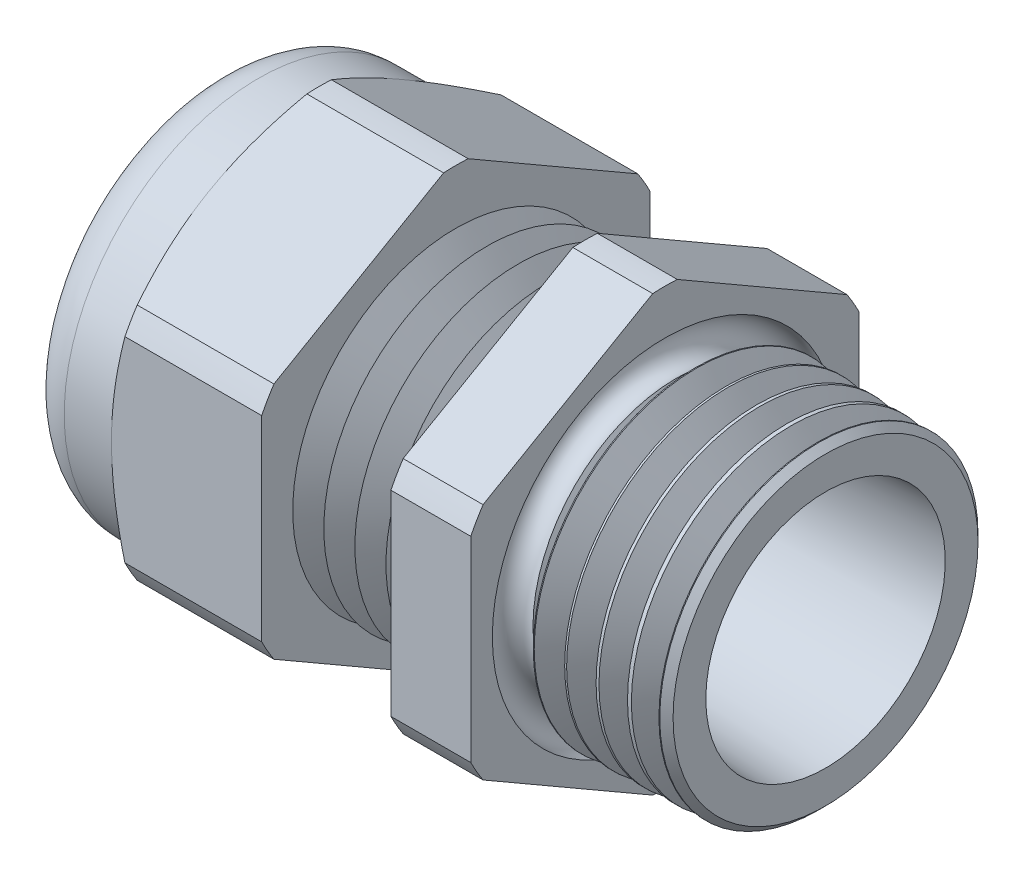
from build123d import *

# Parameters (mm, degrees)
SKETCH2_OUTSIDE_W  = 31.842
SKETCH2_OUTSIDE_H  = 31.842
CUT_EXTRUDE1_DEPTH = 17.62125
CHAMFER1_SIZE      = 0.326149358
CHAMFER1_SIZE2     = 0.3175
SKETCH3_OUTSIDE_W  = 121.118
SKETCH3_OUTSIDE_H  = 123.404
SKETCH3_OUTSIDE_R  = 9.525
CUT_EXTRUDE2_DEPTH = 26.49525
CUT_EXTRUDE2_DRAFT = -60
SKETCH14_W         = 4.47675
SKETCH14_H         = 1.524
FILLET1_R          = 2.159
LPATTERN1_COUNT    = 5
LPATTERN1_PITCH    = 1.524
LPATTERN2_COUNT    = 6
LPATTERN2_PITCH    = 1.524
SKETCH15_R         = 0.8255


with BuildPart() as part:
    # Sketch1 → Revolve1 (revolve)
    with BuildSketch(Plane.XY, mode=Mode.PRIVATE) as revolve1_sk:
        Polygon((-10.25525, 8.001), (-10.25525, 10.668), (-17.62125, 10.668), (-17.62125, 8.001), (-22.098, 8.001), (-22.098, 6.80085), (-17.62125, 6.80085), (-17.62125, 5.08), (-10.25525, 5.08), (7.874, 5.871540149), (7.874, 7.794812054), (0, 8.001), (0, 10.668), (-3.917412935, 10.668), (-3.917412935, 8.001), align=None)
    revolve(revolve1_sk.sketch.rotate(Axis((-18.386021217, 0, 0), (1, 0, 0)), 90), axis=Axis((-18.386021217, 0, 0), (1, 0, 0)))  # turned: the seam where the file's is

    # Sketch2 outside → Cut-Extrude1 (cut)
    with BuildSketch(Plane(origin=(0, 0, 0), x_dir=(0, 0, -1), z_dir=(1, 0, 0))):
        Rectangle(SKETCH2_OUTSIDE_W, SKETCH2_OUTSIDE_H)
        with BuildLine():
            Line((9.525, -4.804227201), (9.525, 4.804227201))
            ThreePointArc((9.525, 4.804227201), (9.238759008, 5.334), (8.923082802, 5.84677837))
            Line((8.923082802, 5.84677837), (0.601917198, 10.651005572))
            ThreePointArc((0.601917198, 10.651005572), (0, 10.668), (-0.601917198, 10.651005572))
            Line((-0.601917198, 10.651005572), (-8.923082802, 5.84677837))
            ThreePointArc((-8.923082802, 5.84677837), (-9.238759008, 5.334), (-9.525, 4.804227201))
            Line((-9.525, 4.804227201), (-9.525, -4.804227201))
            ThreePointArc((-9.525, -4.804227201), (-9.238759008, -5.334), (-8.923082802, -5.84677837))
            Line((-8.923082802, -5.84677837), (-0.601917198, -10.651005572))
            ThreePointArc((-0.601917198, -10.651005572), (0, -10.668), (0.601917198, -10.651005572))
            Line((0.601917198, -10.651005572), (8.923082802, -5.84677837))
            ThreePointArc((8.923082802, -5.84677837), (9.238759008, -5.334), (9.525, -4.804227201))
        make_face(mode=Mode.SUBTRACT)
    extrude(amount=-CUT_EXTRUDE1_DEPTH, mode=Mode.SUBTRACT)

    # Chamfer1
    chamfer1_edges = [part.edges().sort_by_distance(p)[0] for p in [
        (7.874, 0, -7.794812054),
    ]]
    chamfer1_side = [part.faces().sort_by_distance(p)[0] for p in [
        (3.937, 0, -7.897906027),
    ]]
    chamfer(chamfer1_edges, length=CHAMFER1_SIZE, length2=CHAMFER1_SIZE2, reference=chamfer1_side[0])


with BuildPart() as cut_extrude2_tool:
    # Sketch3 outside → Cut-Extrude2 (with draft: the straight prism first)
    with BuildSketch(Plane.ZY.offset(17.62125)):
        Rectangle(SKETCH3_OUTSIDE_W, SKETCH3_OUTSIDE_H)
        Circle(SKETCH3_OUTSIDE_R, mode=Mode.SUBTRACT)
    extrude(amount=-CUT_EXTRUDE2_DEPTH)
    # Cut-Extrude2: the draft: its side faces are tilted about the plane it starts from
    cut_extrude2_sides = [cut_extrude2_tool.faces().sort_by_distance(p)[0] for p in [
        (-4.373625, -61.702, 0),
        (-4.373625, 0, 60.559),
        (-4.373625, 61.702, 0),
        (-4.373625, 0, -60.559),
        (-4.373625, 0, -9.525),
    ]]
    draft(cut_extrude2_sides, Plane.ZY.offset(17.62125), CUT_EXTRUDE2_DRAFT)


with BuildPart() as part_1:
    add(part.part)

    # Cut-Extrude2: cut by cut_extrude2_tool
    add(cut_extrude2_tool.part, mode=Mode.SUBTRACT)

    # Sketch14 → Revolve4 (revolve)
    with BuildSketch(Plane.XY, mode=Mode.PRIVATE) as revolve4_sk:
        with Locations((-19.859625, 8.763)):
            Rectangle(SKETCH14_W, SKETCH14_H)
    revolve(revolve4_sk.sketch.rotate(Axis((-18.386021217, 0, 0), (1, 0, 0)), 90), axis=Axis((-18.386021217, 0, 0), (1, 0, 0)))  # turned: the seam where the file's is

    # Fillet1
    fillet1_edges = [part_1.edges().sort_by_distance(p)[0] for p in [
        (-22.098, 0, -9.525),
    ]]
    fillet(fillet1_edges, radius=FILLET1_R)

    # Sketch10 → Cut-Revolve1 (revolve, cut)
    with BuildSketch(Plane.XY, mode=Mode.PRIVATE) as cut_revolve1_sk:
        Polygon((-10.25525, 8.001), (-9.493250355, 6.6811779), (-8.731250711, 8.001), align=None)
    cut_revolve1 = revolve(cut_revolve1_sk.sketch.rotate(Axis((15.58962545, 0, 0), (-1, 0, 0)), 90), axis=Axis((15.58962545, 0, 0), (-1, 0, 0)), mode=Mode.SUBTRACT)  # turned: the seam where the file's is

    # LPattern1: Cut-Revolve1 ×5
    with Locations(*[(i * LPATTERN1_PITCH, 0, 0) for i in range(1, LPATTERN1_COUNT)]):
        add(cut_revolve1, mode=Mode.SUBTRACT)

    # Sketch13 → Cut-Revolve2 (revolve, cut)
    with BuildSketch(Plane.XY, mode=Mode.PRIVATE) as cut_revolve2_sk:
        Polygon((0, 8.001), (1.523999289, 8.001), (0.761999645, 6.6811779), align=None)
    cut_revolve2 = revolve(cut_revolve2_sk.sketch.rotate(Axis((-18.386021217, 0, 0), (1, 0, 0)), 270), axis=Axis((-18.386021217, 0, 0), (1, 0, 0)), mode=Mode.SUBTRACT)  # turned: the seam where the file's is

    # LPattern2: Cut-Revolve2 ×6
    with Locations(*[(i * LPATTERN2_PITCH, 0, 0) for i in range(1, LPATTERN2_COUNT)]):
        add(cut_revolve2, mode=Mode.SUBTRACT)

    # Sketch15 → Cut-Revolve3 (revolve, cut)
    with BuildSketch(Plane.XY, mode=Mode.PRIVATE) as cut_revolve3_sk:
        with Locations((0, -7.641698712)):
            Circle(SKETCH15_R)
    revolve(cut_revolve3_sk.sketch.rotate(Axis((1.524, 0, 0), (-1, 0, 0)), 270), axis=Axis((1.524, 0, 0), (-1, 0, 0)), mode=Mode.SUBTRACT)  # turned: the seam where the file's is


with BuildPart() as body_2:
    # Sketch9 → Revolve3 (revolve)
    with BuildSketch(Plane.XY, mode=Mode.PRIVATE) as revolve3_sk:
        with BuildLine():
            Line((-21.336, 5.08), (-21.336, 6.54685))
            ThreePointArc((-21.336, 6.54685), (-21.261605122, 6.726455122), (-21.082, 6.80085))
            Line((-21.082, 6.80085), (-17.62125, 6.80085))
            Line((-17.62125, 6.80085), (-17.62125, 5.08))
            Line((-17.62125, 5.08), (-21.336, 5.08))
        make_face()
    revolve(revolve3_sk.sketch.rotate(Axis((8.695207459, 0, 0), (-1, 0, 0)), 270), axis=Axis((8.695207459, 0, 0), (-1, 0, 0)))  # turned: the seam where the file's is


solid = Compound([part_1.part, body_2.part])
